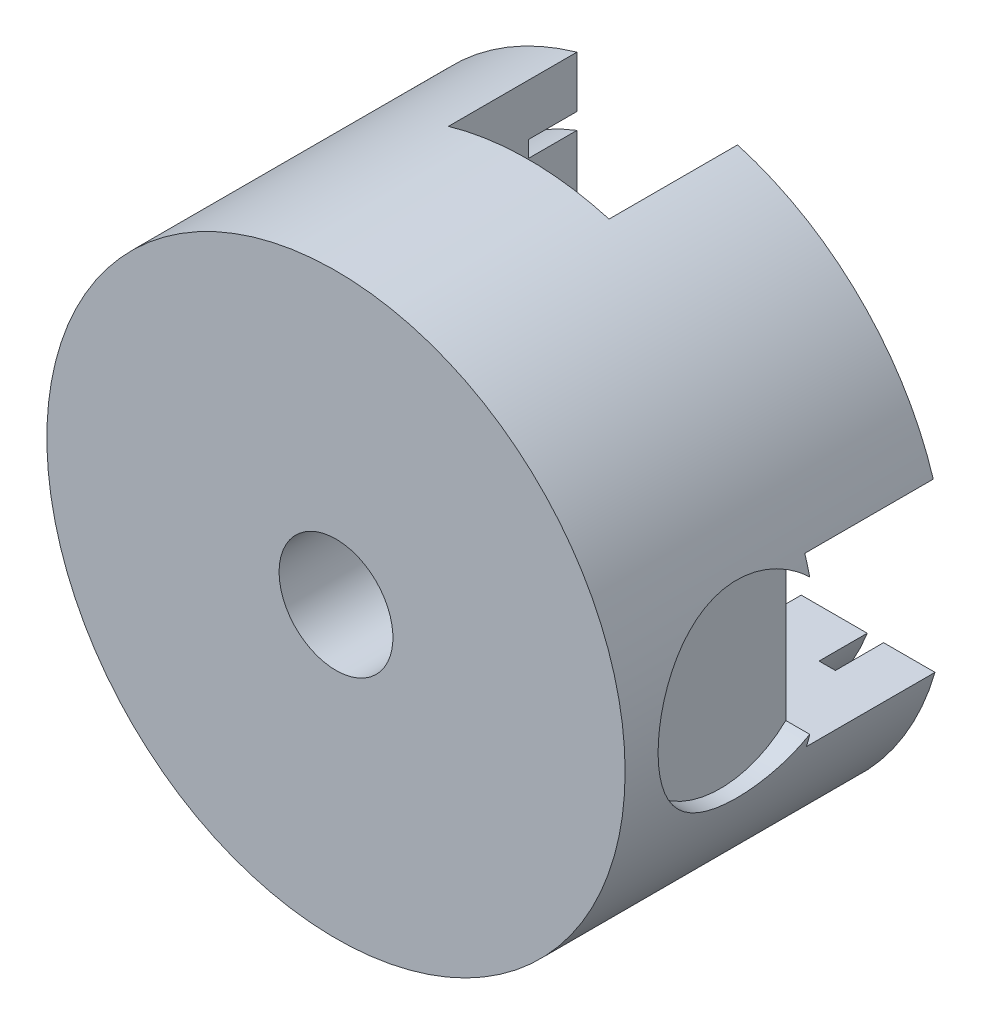
from build123d import *

# Parameters (mm, degrees)
SKETCH1_R           = 180
BOSS_EXTRUDE1_DEPTH = 200
CUT_EXTRUDE1_DEPTH  = 80
SKETCH6_R           = 35.432069659
CUT_EXTRUDE4_DEPTH  = 201
SKETCH7_R           = 149.510464434
SKETCH7_R_2         = 139.963931463
SKETCH7_R_3         = 102.629519035
SKETCH7_R_4         = 93.728776548
CUT_EXTRUDE6_DEPTH  = 30
CUT_EXTRUDE7_START  = 190
SKETCH8_R           = 58.778682825
CUT_EXTRUDE7_DEPTH  = 30
CUT_EXTRUDE8_START  = -150
SKETCH9_R           = 58.778682825
CUT_EXTRUDE8_DEPTH  = 236


with BuildPart() as part:
    # Sketch1 → Boss-Extrude1 (new body)
    with BuildSketch(Plane.XY):
        Circle(SKETCH1_R)
    extrude(amount=BOSS_EXTRUDE1_DEPTH)

    # Sketch2 → Cut-Extrude1 (cut)
    with BuildSketch(Plane(origin=(0, 0, 0), x_dir=(-1, 0, 0), z_dir=(0, 0, -1))):
        Polygon((50, -50), (50, -249.832537204), (-50, -249.832537204), (-50, -50), (-236.119265231, -50), (-236.119265231, 53.613723388), (-50, 53.613723388), (-50, 228.035589712), (50, 228.035589712), (50, 53.613723388), (294.314355645, 53.613723388), (294.314355645, -50), align=None)
    extrude(amount=-CUT_EXTRUDE1_DEPTH, mode=Mode.SUBTRACT)

    # Sketch6 → Cut-Extrude4 (cut, through all)
    with BuildSketch(Plane(origin=(0, 0, 0), x_dir=(-1, 0, 0), z_dir=(0, 0, -1))):
        Circle(SKETCH6_R)
    extrude(amount=-CUT_EXTRUDE4_DEPTH, mode=Mode.SUBTRACT)

    # Sketch7 → Cut-Extrude6 (cut)
    with BuildSketch(Plane(origin=(0, 0, 0), x_dir=(-1, 0, 0), z_dir=(0, 0, -1))):
        Circle(SKETCH7_R)
        Circle(SKETCH7_R_2, mode=Mode.SUBTRACT)
        Circle(SKETCH7_R_3)
        Circle(SKETCH7_R_4, mode=Mode.SUBTRACT)
    extrude(amount=-CUT_EXTRUDE6_DEPTH, mode=Mode.SUBTRACT)

    # Sketch8 → Cut-Extrude7 (cut)
    with BuildSketch(Plane(origin=(0, 0, 0), x_dir=(0, 0, -1), z_dir=(1, 0, 0)).offset(CUT_EXTRUDE7_START)):
        with Locations((-120.694647065, 0)):
            Circle(SKETCH8_R)
    extrude(amount=-CUT_EXTRUDE7_DEPTH, mode=Mode.SUBTRACT)

    # Sketch9 → Cut-Extrude8 (cut)
    with BuildSketch(Plane(origin=(0, 0, 0), x_dir=(0, 0, -1), z_dir=(1, 0, 0)).offset(CUT_EXTRUDE8_START)):
        with Locations((-120.694647065, 0)):
            Circle(SKETCH9_R)
    extrude(amount=-CUT_EXTRUDE8_DEPTH, mode=Mode.SUBTRACT)


solid = part.part
